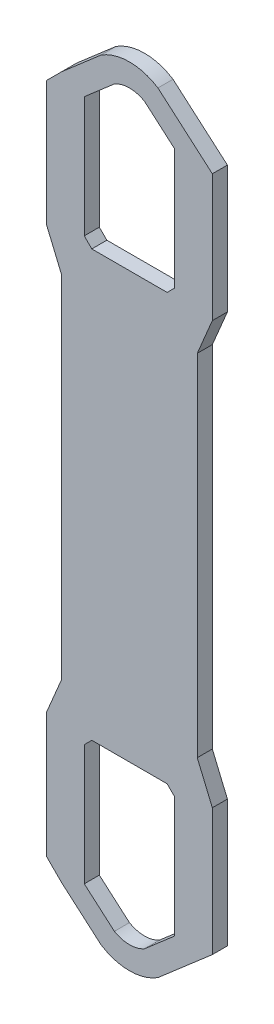
from build123d import *

# Parameters (mm, degrees)
BOSS_EXTRUDE1_DEPTH = 5


with BuildPart() as part:
    # Sketch1 → Boss-Extrude1 (new body)
    with BuildSketch(Plane.XY):
        with BuildLine():
            ThreePointArc((9.444973397, -23.392615611), (0, -26.160254038), (-9.444973397, -23.392615611))
            Line((-9.444973397, -23.392615611), (-22.5, -12.086630926))
            Line((-22.5, -12.086630926), (-22.5, 34.44634768))
            Line((-22.5, 34.44634768), (-15.606601718, 41.339745962))
            Line((-15.606601718, 41.339745962), (15.606601718, 41.339745962))
            Line((15.606601718, 41.339745962), (22.5, 34.44634768))
            Line((22.5, 34.44634768), (22.5, -12.086630926))
            Line((22.5, -12.086630926), (9.444973397, -23.392615611))
        make_face()
        with BuildLine():
            Line((15, -8.660254038), (5, -17.320508076))
            ThreePointArc((5, -17.320508076), (0, -18.660254038), (-5, -17.320508076))
            Line((-5, -17.320508076), (-15, -8.660254038))
            Line((-15, -8.660254038), (-15, 31.339745962))
            Line((-15, 31.339745962), (-12.5, 33.839745962))
            Line((-12.5, 33.839745962), (12.5, 33.839745962))
            Line((12.5, 33.839745962), (15, 31.339745962))
            Line((15, 31.339745962), (15, -8.660254038))
        make_face(mode=Mode.SUBTRACT)
        Polygon((22.5, 174.44634768), (15.606601718, 167.552949398), (-15.606601718, 167.552949398), (-22.5, 174.44634768), (-22.5, 34.44634768), (-15.606601718, 41.339745962), (15.606601718, 41.339745962), (22.5, 34.44634768), align=None)
        with BuildLine():
            Line((22.5, 220.979326286), (9.444973397, 232.285310971))
            ThreePointArc((9.444973397, 232.285310971), (0, 235.052949398), (-9.444973397, 232.285310971))
            Line((-9.444973397, 232.285310971), (-22.5, 220.979326286))
            Line((-22.5, 220.979326286), (-22.5, 174.44634768))
            Line((-22.5, 174.44634768), (-15.606601718, 167.552949398))
            Line((-15.606601718, 167.552949398), (15.606601718, 167.552949398))
            Line((15.606601718, 167.552949398), (22.5, 174.44634768))
            Line((22.5, 174.44634768), (22.5, 220.979326286))
        make_face()
        with BuildLine():
            ThreePointArc((5, 226.213203436), (0, 227.552949398), (-5, 226.213203436))
            Line((-5, 226.213203436), (-15, 217.552949398))
            Line((-15, 217.552949398), (-15, 177.552949398))
            Line((-15, 177.552949398), (-12.5, 175.052949398))
            Line((-12.5, 175.052949398), (12.5, 175.052949398))
            Line((12.5, 175.052949398), (15, 177.552949398))
            Line((15, 177.552949398), (15, 217.552949398))
            Line((15, 217.552949398), (5, 226.213203436))
        make_face(mode=Mode.SUBTRACT)
        Polygon((-22.5, -12.086630926), (-22.5, 34.44634768), (-22.5, 46.339745962), (-27.5, 34.44634768), (-27.5, 29.44634768), (-27.5, -7.086630926), align=None)
        Polygon((22.5, -12.086630926), (27.5, -7.756503907), (27.5, 29.44634768), (22.5, 34.44634768), align=None)
        Polygon((22.5, 46.339745962), (22.5, 34.44634768), (27.5, 29.44634768), (27.5, 34.44634768), align=None)
        Polygon((22.5, 174.44634768), (22.5, 162.552949398), (27.5, 174.44634768), (27.5, 179.44634768), (27.5, 216.649199267), (22.5, 220.979326286), align=None)
        Polygon((-27.5, 174.44634768), (-22.5, 162.552949398), (-22.5, 174.44634768), (-22.5, 220.979326286), (-27.5, 215.979326286), (-27.5, 179.44634768), align=None)
    extrude(amount=BOSS_EXTRUDE1_DEPTH)


solid = part.part
